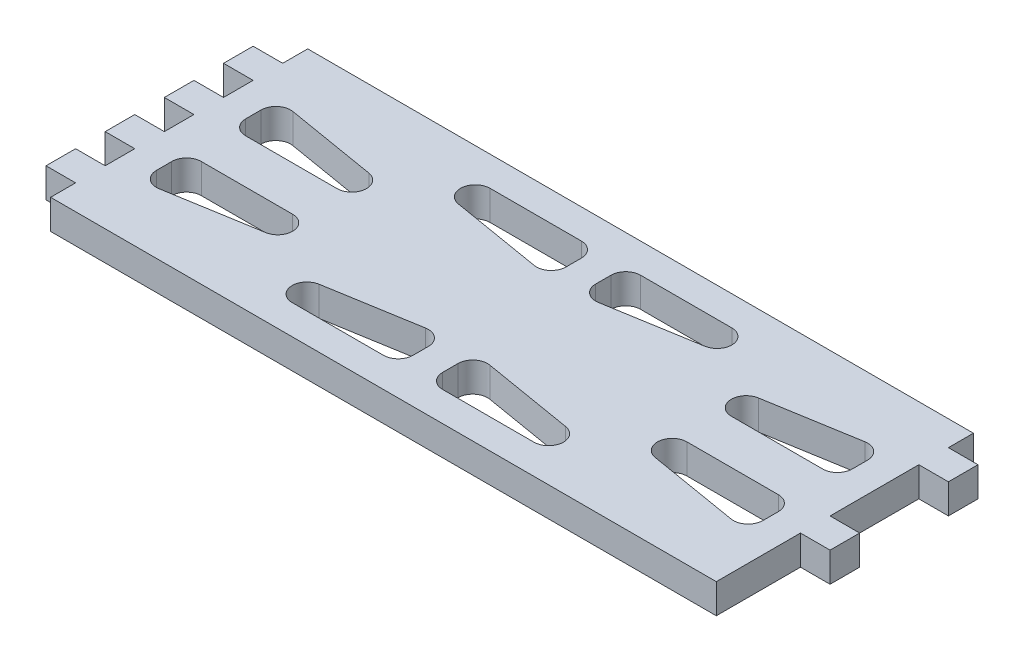
from build123d import *

# Parameters (mm, degrees)
BOSS_EXTRUDE1_DEPTH = 4
CUT_EXTRUDE1_DEPTH  = 10


with BuildPart() as part:
    # Sketch1 → Boss-Extrude1 (new body)
    with BuildSketch(Plane(origin=(0, 0, 0), x_dir=(1, 0, 0), z_dir=(0, 1, 0))):
        Polygon((-13.523809524, 16), (-17.523809524, 16), (-17.523809524, 12), (-13.523809524, 12), (-13.523809524, 8), (-17.523809524, 8), (-17.523809524, 4), (-13.523809524, 4), (-13.523809524, 0), (-17.523809524, 0), (-17.523809524, -4), (-13.523809524, -4), (-13.523809524, -8), (-17.523809524, -8), (-17.523809524, -12), (-13.523809524, -12), (-13.523809524, -15.38), (76.476190476, -15.38), (76.476190476, -4), (80.476190476, -4), (80.476190476, 0), (76.476190476, 0), (76.476190476, 12), (80.476190476, 12), (80.476190476, 16), (76.476190476, 16), (76.476190476, 19.38), (-13.523809524, 19.38), align=None)
    extrude(amount=-BOSS_EXTRUDE1_DEPTH)

    # Sketch2 → Cut-Extrude1 (cut)
    with BuildSketch(Plane(origin=(0, 0, 0), x_dir=(1, 0, 0), z_dir=(0, 1, 0))):
        with BuildLine():
            ThreePointArc((-9.523809524, 9.071498058), (-8.815677287, 10.598284776), (-7.192731841, 11.0439046))
            Line((-7.192731841, 11.0439046), (5.148288204, 8.972406542))
            ThreePointArc((5.148288204, 8.972406542), (6.810300218, 6.833887214), (4.817210521, 5))
            Line((4.817210521, 5), (-7.523809524, 5))
            ThreePointArc((-7.523809524, 5), (-8.938023086, 5.585786438), (-9.523809524, 7))
            Line((-9.523809524, 7), (-9.523809524, 9.071498058))
        make_face()
        with BuildLine():
            Line((15.135170432, 15.38), (27.476190476, 15.38))
            ThreePointArc((27.476190476, 15.38), (28.890404039, 14.794213562), (29.476190476, 13.38))
            Line((29.476190476, 13.38), (29.476190476, 11.308501942))
            ThreePointArc((29.476190476, 11.308501942), (28.768058239, 9.781715224), (27.145112793, 9.3360954))
            Line((27.145112793, 9.3360954), (14.804092749, 11.407593458))
            ThreePointArc((14.804092749, 11.407593458), (13.142080734, 13.546112786), (15.135170432, 15.38))
        make_face()
        with BuildLine():
            Line((33.476190476, 13.38), (33.476190476, 11.308501942))
            ThreePointArc((33.476190476, 11.308501942), (34.184322713, 9.781715224), (35.807268159, 9.3360954))
            Line((35.807268159, 9.3360954), (48.148288204, 11.407593458))
            ThreePointArc((48.148288204, 11.407593458), (49.810300218, 13.546112786), (47.817210521, 15.38))
            Line((47.817210521, 15.38), (35.476190476, 15.38))
            ThreePointArc((35.476190476, 15.38), (34.061976914, 14.794213562), (33.476190476, 13.38))
        make_face()
        with BuildLine():
            ThreePointArc((72.476190476, 7), (71.890404039, 5.585786438), (70.476190476, 5))
            Line((70.476190476, 5), (58.135170432, 5))
            ThreePointArc((58.135170432, 5), (56.142080734, 6.833887214), (57.804092749, 8.972406542))
            Line((57.804092749, 8.972406542), (70.145112793, 11.0439046))
            ThreePointArc((70.145112793, 11.0439046), (71.768058239, 10.598284776), (72.476190476, 9.071498058))
            Line((72.476190476, 9.071498058), (72.476190476, 7))
        make_face()
        with BuildLine():
            ThreePointArc((72.476190476, -5.071498058), (71.768058239, -6.598284776), (70.145112793, -7.0439046))
            Line((70.145112793, -7.0439046), (57.804092749, -4.972406542))
            ThreePointArc((57.804092749, -4.972406542), (56.142080734, -2.833887214), (58.135170432, -1))
            Line((58.135170432, -1), (70.476190476, -1))
            ThreePointArc((70.476190476, -1), (71.890404039, -1.585786438), (72.476190476, -3))
            Line((72.476190476, -3), (72.476190476, -5.071498058))
        make_face()
        with BuildLine():
            Line((47.817210521, -11.38), (35.476190476, -11.38))
            ThreePointArc((35.476190476, -11.38), (34.061976914, -10.794213562), (33.476190476, -9.38))
            Line((33.476190476, -9.38), (33.476190476, -7.308501942))
            ThreePointArc((33.476190476, -7.308501942), (34.184322713, -5.781715224), (35.807268159, -5.3360954))
            Line((35.807268159, -5.3360954), (48.148288204, -7.407593458))
            ThreePointArc((48.148288204, -7.407593458), (49.810300218, -9.546112786), (47.817210521, -11.38))
        make_face()
        with BuildLine():
            Line((29.476190476, -9.38), (29.476190476, -7.308501942))
            ThreePointArc((29.476190476, -7.308501942), (28.768058239, -5.781715224), (27.145112793, -5.3360954))
            Line((27.145112793, -5.3360954), (14.804092749, -7.407593458))
            ThreePointArc((14.804092749, -7.407593458), (13.142080734, -9.546112786), (15.135170432, -11.38))
            Line((15.135170432, -11.38), (27.476190476, -11.38))
            ThreePointArc((27.476190476, -11.38), (28.890404039, -10.794213562), (29.476190476, -9.38))
        make_face()
        with BuildLine():
            ThreePointArc((-9.523809524, -3), (-8.938023086, -1.585786438), (-7.523809524, -1))
            Line((-7.523809524, -1), (4.817210521, -1))
            ThreePointArc((4.817210521, -1), (6.810300218, -2.833887214), (5.148288204, -4.972406542))
            Line((5.148288204, -4.972406542), (-7.192731841, -7.0439046))
            ThreePointArc((-7.192731841, -7.0439046), (-8.815677287, -6.598284776), (-9.523809524, -5.071498058))
            Line((-9.523809524, -5.071498058), (-9.523809524, -3))
        make_face()
    extrude(amount=-CUT_EXTRUDE1_DEPTH, mode=Mode.SUBTRACT)


solid = part.part
